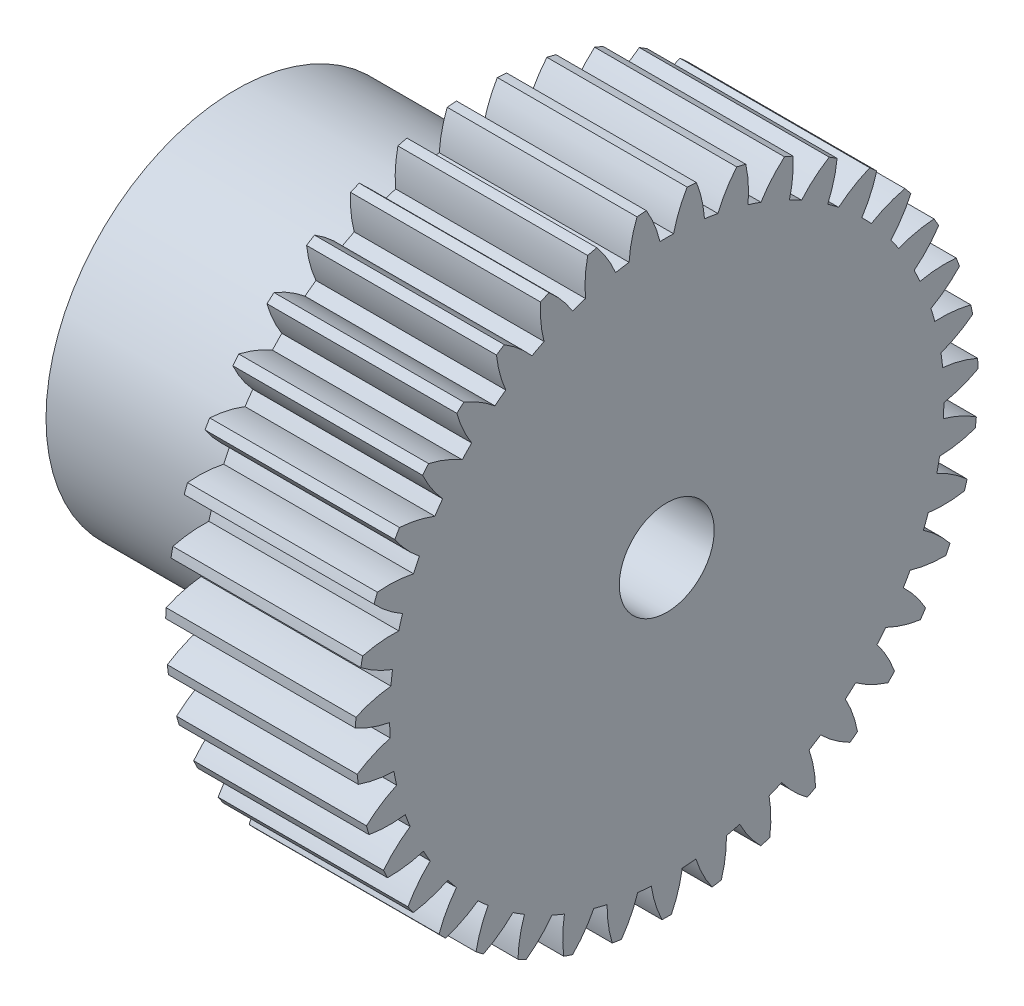
from build123d import *

# Parameters (mm, degrees)
BASPROSKE_W      = 10
BASPROSKE_H      = 16.4
TOOTHCUT_DEPTH   = 26.257078216
TEETHCUTS_COUNT  = 39
TEETHCUTS_ANGLE  = 350.769230769
HUBNEAONESKE_R   = 10
HUBNEARONE_DEPTH = 12.7000508
BORSKE_R         = 2.5
BORE_DEPTH       = 10.0000508


with BuildPart() as part:
    # BasProSke → Base-Revolve (revolve)
    with BuildSketch(Plane(origin=(0, 0, 0), x_dir=(1, 0, 0), z_dir=(0, 1, 0)), mode=Mode.PRIVATE) as base_revolve_sk:
        with Locations((5, 8.2)):
            Rectangle(BASPROSKE_W, BASPROSKE_H)
    revolve(base_revolve_sk.sketch.rotate(Axis((-10, 0, 0), (1, 0, 0)), 180), axis=Axis((-10, 0, 0), (1, 0, 0)))

    # TooCutSke → ToothCut (cut, through all)
    with BuildSketch(Plane(origin=(0, 0, 0), x_dir=(0, 0, -1), z_dir=(1, 0, 0))):
        with BuildLine():
            ThreePointArc((0.35934894, 14.59457671), (0, 14.599), (-0.35934894, 14.59457671))
            ThreePointArc((-0.35934894, 14.59457671), (-0.653910463, 15.520403912), (-1.088613769, 16.389285684))
            ThreePointArc((-1.088613769, 16.389285684), (0, 16.4254), (1.088613769, 16.389285684))
            ThreePointArc((1.088613769, 16.389285684), (0.653910463, 15.520403912), (0.35934894, 14.59457671))
        make_face()
    toothcut = extrude(amount=TOOTHCUT_DEPTH, mode=Mode.SUBTRACT)

    # TeethCuts: ToothCut ×39 about axis
    teethcuts_axis = Axis((-10, 0, 0), (1, 0, 0))
    for i in range(1, TEETHCUTS_COUNT):
        add(toothcut.rotate(teethcuts_axis, i * TEETHCUTS_ANGLE / (TEETHCUTS_COUNT - 1)), mode=Mode.SUBTRACT)

    # HubNeaOneSke → HubNearOne (add)
    with BuildSketch(Plane.ZY):
        with Locations(Location((0, 0, 0), (0, 0, 180))):
            Circle(HUBNEAONESKE_R)
    extrude(amount=HUBNEARONE_DEPTH)

    # BorSke → Bore (cut, symmetric)
    with BuildSketch(Plane(origin=(0, 0, 0), x_dir=(0, 0, -1), z_dir=(1, 0, 0))):
        with Locations(Location((0, 0, 0), (0, 0, 180))):
            Circle(BORSKE_R)
    extrude(amount=BORE_DEPTH, both=True, mode=Mode.SUBTRACT)


solid = part.part
